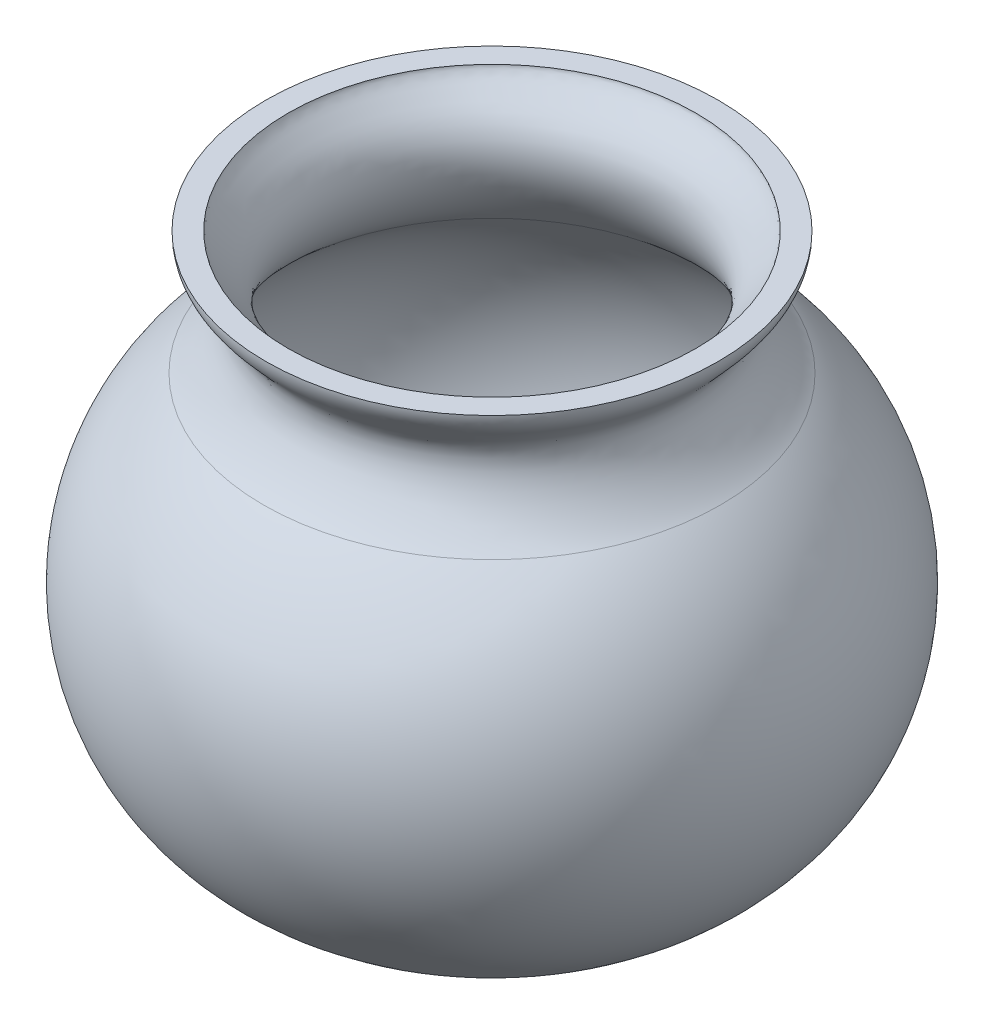
from build123d import *

# Parameters (mm, degrees)
CUT_EXTRUDE1_REACH = 43.881
SKETCH2_R          = 1.25


with BuildPart() as part:
    # Sketch1 → Revolve2 (revolve)
    with BuildSketch(Plane.XY):
        with BuildLine():
            Line((0, -23.695334094), (6.496845792, -23.695334094))
            ThreePointArc((6.496845792, -23.695334094), (23.589920443, -11.588612331), (17.841726544, 8.553487355))
            add(Edge.make_bspline(
                [(17.841726544, 8.553487355), (16.3632375, 9.740649313), (13.054157045, 14.383133743), (17.676030793, 16.543549217), (17.676030793, 18.185269345)],
                knots=[0, 0, 0, 0, 0.574289638, 1, 1, 1, 1], degree=3))
            Line((17.676030793, 18.185269345), (15.926030793, 18.185269345))
            add(Edge.make_bspline(
                [(16.746052288, 7.188936907), (16.53304904, 7.359969188), (16.132410921, 7.715927698), (15.32957285, 8.555605006), (14.396139636, 9.788570246), (13.662803268, 11.228641297), (13.316734428, 12.519745025), (13.232604166, 13.564004203), (13.415078537, 14.695626089), (13.942863241, 15.727062408), (14.526560351, 16.443911071), (15.077148434, 17.024570972), (15.528063865, 17.501195005), (15.820110703, 17.878855972), (15.922120781, 18.105017005), (15.926030793, 18.149005829), (15.926030793, 18.185269345)],
                knots=[0, 0, 0, 0, 0.0625, 0.125, 0.25, 0.375, 0.4375, 0.5, 0.5625, 0.625, 0.6875, 0.75, 0.8125, 0.875, 0.9375, 1, 1, 1, 1], degree=3))
            ThreePointArc((16.746052288, 7.188936907), (21.939092881, -11.007864229), (6.496845792, -21.945334094))
            Line((6.496845792, -21.945334094), (0, -21.945334094))
            Line((0, -21.945334094), (0, -23.695334094))
        make_face()
    revolve(axis=Axis((0, 58.522079392, 0), (0, -1, 0)))

    # Sketch2 → Cut-Extrude1 (cut, up to next)
    with BuildSketch(Plane.XZ.offset(23.695334094), mode=Mode.PRIVATE) as cut_extrude1_sk1:
        with Locations((2.25, 2.25)):
            Circle(SKETCH2_R)
    cut_extrude1_tool1 = extrude(cut_extrude1_sk1.sketch, amount=-CUT_EXTRUDE1_REACH, mode=Mode.PRIVATE) & part.part
    add(cut_extrude1_tool1.solids().sort_by_distance((2.25, -23.695334, 2.25))[0], mode=Mode.SUBTRACT)
    # Sketch2 → Cut-Extrude1 (cut, up to next)
    with BuildSketch(Plane.XZ.offset(23.695334094), mode=Mode.PRIVATE) as cut_extrude1_sk2:
        with Locations((-2.25, 2.25)):
            Circle(SKETCH2_R)
    cut_extrude1_tool2 = extrude(cut_extrude1_sk2.sketch, amount=-CUT_EXTRUDE1_REACH, mode=Mode.PRIVATE) & part.part
    add(cut_extrude1_tool2.solids().sort_by_distance((-2.25, -23.695334, 2.25))[0], mode=Mode.SUBTRACT)
    # Sketch2 → Cut-Extrude1 (cut, up to next)
    with BuildSketch(Plane.XZ.offset(23.695334094), mode=Mode.PRIVATE) as cut_extrude1_sk3:
        with Locations((2.25, -2.25)):
            Circle(SKETCH2_R)
    cut_extrude1_tool3 = extrude(cut_extrude1_sk3.sketch, amount=-CUT_EXTRUDE1_REACH, mode=Mode.PRIVATE) & part.part
    add(cut_extrude1_tool3.solids().sort_by_distance((2.25, -23.695334, -2.25))[0], mode=Mode.SUBTRACT)
    # Sketch2 → Cut-Extrude1 (cut, up to next)
    with BuildSketch(Plane.XZ.offset(23.695334094), mode=Mode.PRIVATE) as cut_extrude1_sk4:
        with Locations((-2.25, -2.25)):
            Circle(SKETCH2_R)
    cut_extrude1_tool4 = extrude(cut_extrude1_sk4.sketch, amount=-CUT_EXTRUDE1_REACH, mode=Mode.PRIVATE) & part.part
    add(cut_extrude1_tool4.solids().sort_by_distance((-2.25, -23.695334, -2.25))[0], mode=Mode.SUBTRACT)


solid = part.part
